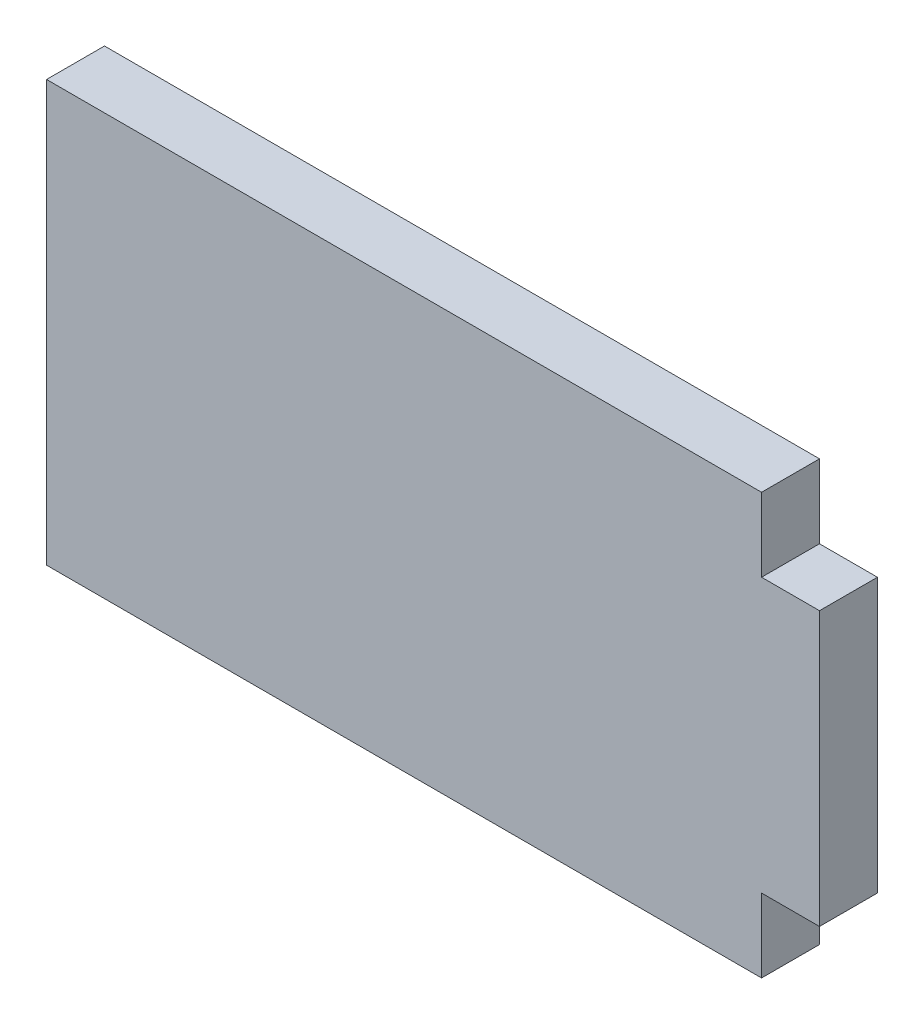
from build123d import *

# Parameters (mm, degrees)
BOSS_EXTRUDE1_DEPTH = 3


with BuildPart() as part:
    # Sketch1 → Boss-Extrude1 (new body)
    with BuildSketch(Plane.XY):
        Polygon((0, 21.78), (37.02, 21.78), (37.02, 17.97), (40.02, 17.97), (40.02, 3.81), (37.02, 3.81), (37.02, 0), (0, 0), align=None)
    extrude(amount=BOSS_EXTRUDE1_DEPTH)


solid = part.part
